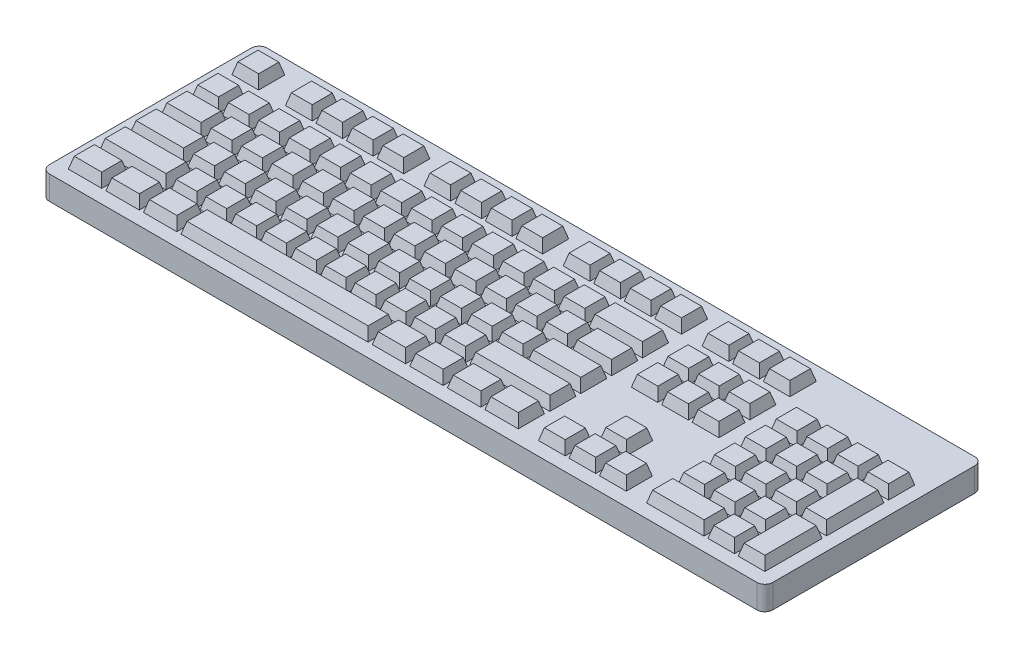
from build123d import *

# Parameters (mm, degrees)
BOSS_EXTRUDE1_DEPTH = 15
SKETCH6_W           = 16.80763
SKETCH6_H           = 16.429976
SKETCH6_W_2         = 16.807613
SKETCH6_W_3         = 16.807598
SKETCH6_W_4         = 16.807596
SKETCH6_W_5         = 16.807599
SKETCH6_W_6         = 16.634378
SKETCH6_H_2         = 16.603197
SKETCH6_W_7         = 16.807597
SKETCH6_W_8         = 16.807267
SKETCH6_W_9         = 16.80728
SKETCH6_W_10        = 16.80731
SKETCH6_W_11        = 16.8073
SKETCH6_W_12        = 16.63408
SKETCH6_H_3         = 16.634377
SKETCH6_H_4         = 16.429975
SKETCH6_W_13        = 16.80764
SKETCH6_W_14        = 16.807594
SKETCH6_W_15        = 16.807595
SKETCH6_W_16        = 16.807252
SKETCH6_W_17        = 16.80727
SKETCH6_W_18        = 33.61523
SKETCH6_W_19        = 16.63409
SKETCH6_H_5         = 16.634375
SKETCH6_W_20        = 16.80726
SKETCH6_W_21        = 16.80729
SKETCH6_W_22        = 16.63407
SKETCH6_H_6         = 36.034044
SKETCH6_H_7         = 35.99561
SKETCH6_H_8         = 16.429629
SKETCH6_H_9         = 16.634032
SKETCH6_H_10        = 16.429647
SKETCH6_W_23        = 36.12936
SKETCH6_H_11        = 16.42965
SKETCH6_W_24        = 25.21126
SKETCH6_W_25        = 16.80762
SKETCH6_W_26        = 16.8076
SKETCH6_W_27        = 33.61662
SKETCH6_W_28        = 16.807611
SKETCH6_W_29        = 42.020218
SKETCH6_W_30        = 16.807249
SKETCH6_W_31        = 50.42211
SKETCH6_W_32        = 21.00962
SKETCH6_W_33        = 21.0096
SKETCH6_W_34        = 21.009584
SKETCH6_W_35        = 117.652488
SKETCH6_W_36        = 21.009583
SKETCH6_W_37        = 21.009237
SKETCH6_W_38        = 21.00926
SKETCH6_W_39        = 21.00927
BOSS_EXTRUDE3_DEPTH = 7
BOSS_EXTRUDE3_TAPER = 15


with BuildPart() as part:
    # Sketch4 → Boss-Extrude1 (new body)
    with BuildSketch(Plane(origin=(0, 0, 0), x_dir=(1, 0, 0), z_dir=(0, 1, 0))):
        with BuildLine():
            Line((5.10038, 137.07767), (450.10036, 137.07767))
            ThreePointArc((450.10036, 137.07767), (453.635893906, 135.613203906), (455.10036, 132.07767))
            Line((455.10036, 132.07767), (455.10036, 5.100004))
            ThreePointArc((455.10036, 5.100004), (453.635893906, 1.564470094), (450.10036, 0.100004))
            Line((450.10036, 0.100004), (5.10038, 0.100004))
            ThreePointArc((5.10038, 0.100004), (1.564846094, 1.564470094), (0.10038, 5.100004))
            Line((0.10038, 5.100004), (0.10038, 132.07767))
            ThreePointArc((0.10038, 132.07767), (1.564846094, 135.613203906), (5.10038, 137.07767))
        make_face()
    extrude(amount=-BOSS_EXTRUDE1_DEPTH)

    # Sketch6 → Boss-Extrude3 (add)
    with BuildSketch(Plane(origin=(0, 0, 0), x_dir=(1, 0, 0), z_dir=(0, 1, 0))):
        with Locations((16.907785, 119.765136)):
            Rectangle(SKETCH6_W, SKETCH6_H)
        with Locations((50.5687165, 119.765136)):
            Rectangle(SKETCH6_W_2, SKETCH6_H)
        with Locations((69.76261, 119.765136)):
            Rectangle(SKETCH6_W_3, SKETCH6_H)
        with Locations((88.95684, 119.765136)):
            Rectangle(SKETCH6_W_4, SKETCH6_H)
        with Locations((108.1541875, 119.765136)):
            Rectangle(SKETCH6_W_5, SKETCH6_H)
        with Locations((137.8151, 119.6785255)):
            Rectangle(SKETCH6_W_6, SKETCH6_H_2)
        with Locations((157.0955925, 119.765136)):
            Rectangle(SKETCH6_W_7, SKETCH6_H)
        with Locations((176.289825, 119.765136)):
            Rectangle(SKETCH6_W_3, SKETCH6_H)
        with Locations((195.486824, 119.765136)):
            Rectangle(SKETCH6_W_3, SKETCH6_H)
        with Locations((225.23504, 119.765136)):
            Rectangle(SKETCH6_W_4, SKETCH6_H)
        with Locations((244.4290865, 119.765136)):
            Rectangle(SKETCH6_W_8, SKETCH6_H)
        with Locations((263.62644, 119.765136)):
            Rectangle(SKETCH6_W_9, SKETCH6_H)
        with Locations((282.82378, 119.765136)):
            Rectangle(SKETCH6_W_9, SKETCH6_H)
        with Locations((312.565055, 119.765136)):
            Rectangle(SKETCH6_W_10, SKETCH6_H)
        with Locations((331.7624, 119.765136)):
            Rectangle(SKETCH6_W_11, SKETCH6_H)
        with Locations((351.04602, 119.8673365)):
            Rectangle(SKETCH6_W_12, SKETCH6_H_3)
        with Locations((16.907785, 94.5542605)):
            Rectangle(SKETCH6_W, SKETCH6_H_4)
        with Locations((36.10513, 94.5542605)):
            Rectangle(SKETCH6_W_13, SKETCH6_H_4)
        with Locations((55.299037, 94.5542605)):
            Rectangle(SKETCH6_W_14, SKETCH6_H_4)
        with Locations((74.493264, 94.5542605)):
            Rectangle(SKETCH6_W_3, SKETCH6_H_4)
        with Locations((93.6906125, 94.5542605)):
            Rectangle(SKETCH6_W_5, SKETCH6_H_4)
        with Locations((112.887613, 94.5542605)):
            Rectangle(SKETCH6_W_3, SKETCH6_H_4)
        with Locations((132.081844, 94.5542605)):
            Rectangle(SKETCH6_W_14, SKETCH6_H_4)
        with Locations((151.275729, 94.5542605)):
            Rectangle(SKETCH6_W_4, SKETCH6_H_4)
        with Locations((170.4730755, 94.5542605)):
            Rectangle(SKETCH6_W_15, SKETCH6_H_4)
        with Locations((189.669729, 94.5542605)):
            Rectangle(SKETCH6_W_3, SKETCH6_H_4)
        with Locations((208.860843, 94.5542605)):
            Rectangle(SKETCH6_W_4, SKETCH6_H_4)
        with Locations((228.058364, 94.5542605)):
            Rectangle(SKETCH6_W_16, SKETCH6_H_4)
        with Locations((247.251545, 94.5542605)):
            Rectangle(SKETCH6_W_17, SKETCH6_H_4)
        with Locations((275.076315, 94.5542605)):
            Rectangle(SKETCH6_W_18, SKETCH6_H_4)
        with Locations((312.565055, 94.5542605)):
            Rectangle(SKETCH6_W_10, SKETCH6_H_4)
        with Locations((331.7624, 94.5542605)):
            Rectangle(SKETCH6_W_11, SKETCH6_H_4)
        with Locations((350.95941, 94.5542605)):
            Rectangle(SKETCH6_W_11, SKETCH6_H_4)
        with Locations((312.651665, 75.2422415)):
            Rectangle(SKETCH6_W_19, SKETCH6_H_5)
        with Locations((331.7624, 75.1400415)):
            Rectangle(SKETCH6_W_11, SKETCH6_H_4)
        with Locations((350.95941, 75.1400415)):
            Rectangle(SKETCH6_W_11, SKETCH6_H_4)
        with Locations((380.71423, 94.5542605)):
            Rectangle(SKETCH6_W_20, SKETCH6_H_4)
        with Locations((399.898045, 94.5542605)):
            Rectangle(SKETCH6_W_17, SKETCH6_H_4)
        with Locations((419.095045, 94.5542605)):
            Rectangle(SKETCH6_W_21, SKETCH6_H_4)
        with Locations((438.292385, 94.5542605)):
            Rectangle(SKETCH6_W_21, SKETCH6_H_4)
        with Locations((380.71423, 75.1400415)):
            Rectangle(SKETCH6_W_20, SKETCH6_H_4)
        with Locations((399.984645, 75.2422415)):
            Rectangle(SKETCH6_W_22, SKETCH6_H_5)
        with Locations((419.095045, 75.1400415)):
            Rectangle(SKETCH6_W_21, SKETCH6_H_4)
        with Locations((438.292385, 65.338351)):
            Rectangle(SKETCH6_W_21, SKETCH6_H_6)
        with Locations((438.292385, 26.530189)):
            Rectangle(SKETCH6_W_21, SKETCH6_H_7)
        with Locations((380.71423, 55.7266855)):
            Rectangle(SKETCH6_W_20, SKETCH6_H_8)
        with Locations((399.898045, 55.828887)):
            Rectangle(SKETCH6_W_17, SKETCH6_H_9)
        with Locations((419.095045, 55.7266855)):
            Rectangle(SKETCH6_W_21, SKETCH6_H_8)
        with Locations((380.71423, 36.3124775)):
            Rectangle(SKETCH6_W_20, SKETCH6_H_10)
        with Locations((399.898045, 36.3124775)):
            Rectangle(SKETCH6_W_17, SKETCH6_H_10)
        with Locations((419.095045, 36.3124775)):
            Rectangle(SKETCH6_W_21, SKETCH6_H_10)
        with Locations((390.23354, 16.898599)):
            Rectangle(SKETCH6_W_23, SKETCH6_H_11)
        with Locations((419.095045, 16.898599)):
            Rectangle(SKETCH6_W_21, SKETCH6_H_11)
        with Locations((331.7624, 36.3055475)):
            Rectangle(SKETCH6_W_11, SKETCH6_H_10)
        with Locations((350.95941, 16.892019)):
            Rectangle(SKETCH6_W_11, SKETCH6_H_11)
        with Locations((331.7624, 16.892019)):
            Rectangle(SKETCH6_W_11, SKETCH6_H_11)
        with Locations((312.565055, 16.892019)):
            Rectangle(SKETCH6_W_10, SKETCH6_H_11)
        with Locations((21.1096, 75.1400415)):
            Rectangle(SKETCH6_W_24, SKETCH6_H_4)
        with Locations((44.72529, 75.1400415)):
            Rectangle(SKETCH6_W_25, SKETCH6_H_4)
        with Locations((63.899784, 75.1400415)):
            Rectangle(SKETCH6_W_3, SKETCH6_H_4)
        with Locations((83.0773865, 75.1400415)):
            Rectangle(SKETCH6_W_15, SKETCH6_H_4)
        with Locations((102.2515225, 75.1400415)):
            Rectangle(SKETCH6_W_7, SKETCH6_H_4)
        with Locations((121.429123, 75.1400415)):
            Rectangle(SKETCH6_W_4, SKETCH6_H_4)
        with Locations((140.603258, 75.1400415)):
            Rectangle(SKETCH6_W_26, SKETCH6_H_4)
        with Locations((159.7812065, 75.1400415)):
            Rectangle(SKETCH6_W_7, SKETCH6_H_4)
        with Locations((178.955344, 75.1400415)):
            Rectangle(SKETCH6_W_4, SKETCH6_H_4)
        with Locations((198.132943, 75.1400415)):
            Rectangle(SKETCH6_W_3, SKETCH6_H_4)
        with Locations((217.3105455, 75.1400415)):
            Rectangle(SKETCH6_W_15, SKETCH6_H_4)
        with Locations((236.484854, 75.1400415)):
            Rectangle(SKETCH6_W_16, SKETCH6_H_4)
        with Locations((255.655855, 75.1400415)):
            Rectangle(SKETCH6_W_21, SKETCH6_H_4)
        with Locations((279.27796, 75.1400415)):
            Rectangle(SKETCH6_W_24, SKETCH6_H_4)
        with Locations((25.31262, 55.7195845)):
            Rectangle(SKETCH6_W_27, SKETCH6_H_4)
        with Locations((53.1292655, 55.7195845)):
            Rectangle(SKETCH6_W_28, SKETCH6_H_4)
        with Locations((72.543148, 55.7195845)):
            Rectangle(SKETCH6_W_3, SKETCH6_H_4)
        with Locations((91.9535565, 55.7195845)):
            Rectangle(SKETCH6_W_15, SKETCH6_H_4)
        with Locations((111.3677765, 55.7195845)):
            Rectangle(SKETCH6_W_15, SKETCH6_H_4)
        with Locations((130.7781855, 55.7195845)):
            Rectangle(SKETCH6_W_7, SKETCH6_H_4)
        with Locations((150.1924045, 55.7195845)):
            Rectangle(SKETCH6_W_7, SKETCH6_H_4)
        with Locations((169.605934, 55.7195845)):
            Rectangle(SKETCH6_W_3, SKETCH6_H_4)
        with Locations((189.020154, 55.7195845)):
            Rectangle(SKETCH6_W_3, SKETCH6_H_4)
        with Locations((208.427445, 55.7195845)):
            Rectangle(SKETCH6_W_4, SKETCH6_H_4)
        with Locations((227.84149, 55.7195845)):
            Rectangle(SKETCH6_W_16, SKETCH6_H_4)
        with Locations((247.251545, 55.7195845)):
            Rectangle(SKETCH6_W_17, SKETCH6_H_4)
        with Locations((275.076315, 55.7195845)):
            Rectangle(SKETCH6_W_18, SKETCH6_H_4)
        with Locations((29.514099, 36.3055475)):
            Rectangle(SKETCH6_W_29, SKETCH6_H_10)
        with Locations((61.532899, 36.3055475)):
            Rectangle(SKETCH6_W_3, SKETCH6_H_10)
        with Locations((80.299967, 36.3055475)):
            Rectangle(SKETCH6_W_4, SKETCH6_H_10)
        with Locations((99.0704965, 36.3055475)):
            Rectangle(SKETCH6_W_5, SKETCH6_H_10)
        with Locations((117.837912, 36.3055475)):
            Rectangle(SKETCH6_W_4, SKETCH6_H_10)
        with Locations((136.604983, 36.3055475)):
            Rectangle(SKETCH6_W_4, SKETCH6_H_10)
        with Locations((155.375514, 36.3055475)):
            Rectangle(SKETCH6_W_14, SKETCH6_H_10)
        with Locations((174.1429285, 36.3055475)):
            Rectangle(SKETCH6_W_15, SKETCH6_H_10)
        with Locations((192.9068775, 36.3055475)):
            Rectangle(SKETCH6_W_7, SKETCH6_H_10)
        with Locations((211.677409, 36.3055475)):
            Rectangle(SKETCH6_W_4, SKETCH6_H_10)
        with Locations((230.4474235, 36.3055475)):
            Rectangle(SKETCH6_W_30, SKETCH6_H_10)
        with Locations((266.672875, 36.3055475)):
            Rectangle(SKETCH6_W_31, SKETCH6_H_10)
        with Locations((19.00843, 16.892019)):
            Rectangle(SKETCH6_W_32, SKETCH6_H_11)
        with Locations((42.62811, 16.892019)):
            Rectangle(SKETCH6_W_33, SKETCH6_H_11)
        with Locations((66.246749, 16.892019)):
            Rectangle(SKETCH6_W_34, SKETCH6_H_11)
        with Locations((138.187176, 16.892019)):
            Rectangle(SKETCH6_W_35, SKETCH6_H_11)
        with Locations((210.1279505, 16.892019)):
            Rectangle(SKETCH6_W_36, SKETCH6_H_11)
        with Locations((233.7405185, 16.892019)):
            Rectangle(SKETCH6_W_37, SKETCH6_H_11)
        with Locations((257.3626, 16.892019)):
            Rectangle(SKETCH6_W_38, SKETCH6_H_11)
        with Locations((280.972215, 16.892019)):
            Rectangle(SKETCH6_W_39, SKETCH6_H_11)
    extrude(amount=BOSS_EXTRUDE3_DEPTH, taper=BOSS_EXTRUDE3_TAPER)


solid = part.part
